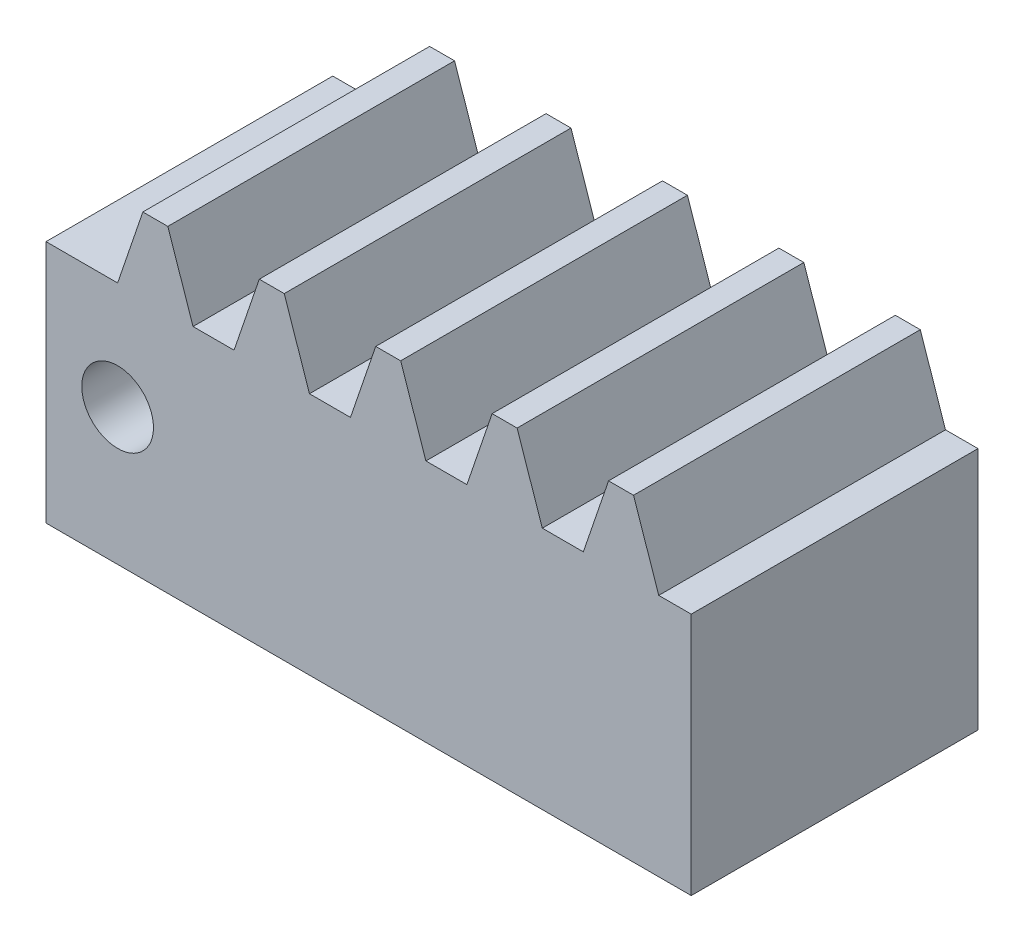
from build123d import *

# Parameters (mm, degrees)
SKETCH1_R        = 3.175
EXTRUSION1_DEPTH = 25.4


with BuildPart() as part:
    # Sketch1 → Extrusion1 (new body)
    with BuildSketch(Plane.XY):
        Polygon((6.35, 0), (63.5, 0), (63.5, 21.59), (59.69, 21.59), (6.35, 21.59), align=None)
        with Locations((12.693410129, 12.073465073)):
            Circle(SKETCH1_R, mode=Mode.SUBTRACT)
        Polygon((14.928610129, 28.154355163), (12.693410129, 21.59), (16.503410129, 21.59), (19.373610129, 21.59), (17.138410129, 28.154355163), (16.033510129, 28.154355163), align=None)
        Polygon((25.241010129, 28.154355163), (23.005810129, 21.59), (29.686010129, 21.59), (27.450810129, 28.154355163), (26.345910129, 28.154355163), align=None)
        Polygon((59.69, 21.59), (60.623210129, 21.59), (58.388010129, 28.154355163), (57.283110129, 28.154355163), (56.178210129, 28.154355163), (53.943010129, 21.59), align=None)
        Polygon((43.630610129, 21.59), (50.310810129, 21.59), (48.075610129, 28.154355163), (46.970710129, 28.154355163), (45.865810129, 28.154355163), align=None)
        Polygon((39.996666979, 21.59), (39.998410129, 21.59), (37.763210129, 28.154355163), (36.658310129, 28.154355163), (35.553410129, 28.154355163), (33.318210129, 21.59), (36.186666979, 21.59), align=None)
    extrude(amount=EXTRUSION1_DEPTH)


solid = part.part
